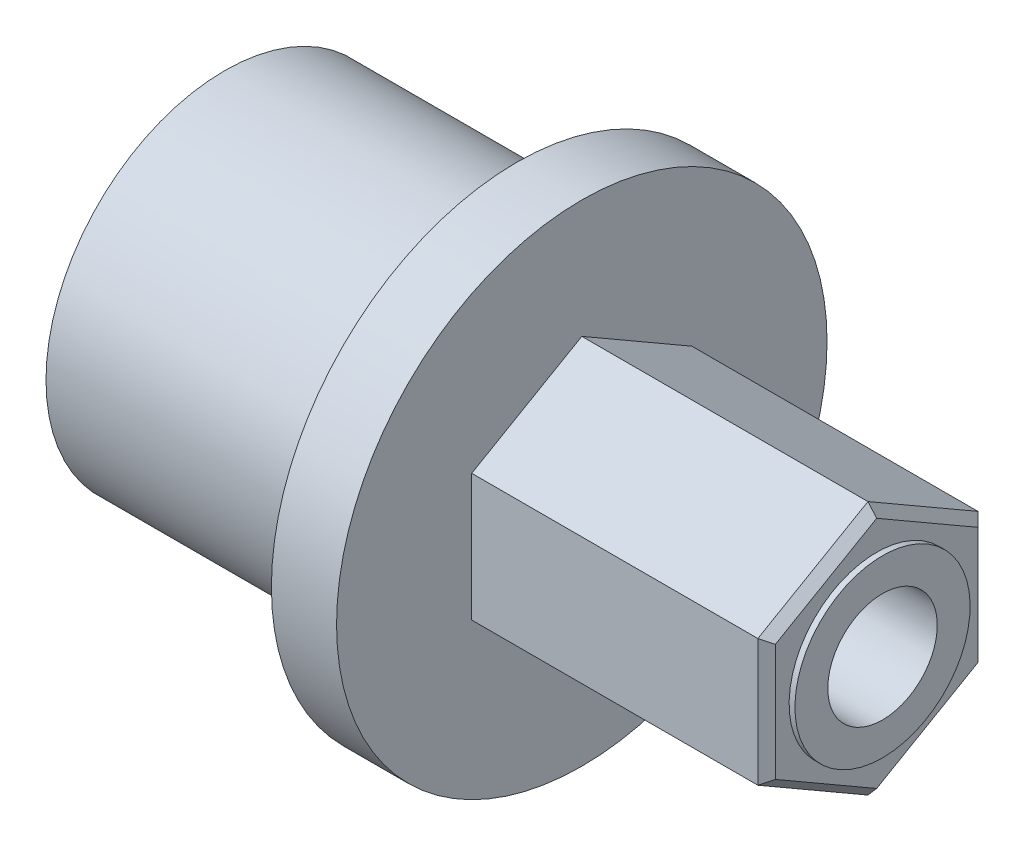
from build123d import *

# Parameters (mm, degrees)
SKETCH3_R           = 3.81
BOSS_EXTRUDE1_DEPTH = 12.827
CHAMFER1_SIZE       = 0.381


with BuildPart() as part:
    # Sketch1 → Revolve1 (revolve)
    with BuildSketch(Plane.XY):
        Polygon((-12.8778, 10.668), (-12.8778, 3.81), (0.2032, 3.81), (0.2032, 2.38125), (-24.036969082, 2.38125), (-28.412119082, 6.7564), (-28.412119082, 7.7724), (-15.712119082, 7.7724), (-15.712119082, 10.668), align=None)
    revolve(axis=Axis((-22.598839253, 0, 0), (1, 0, 0)))

    # Sketch3 → Boss-Extrude1 (add)
    with BuildSketch(Plane(origin=(-12.8778, 0, 0), x_dir=(0, 0, -1), z_dir=(1, 0, 0))):
        Polygon((-4.7879, 2.764295354), (-4.7879, -2.764295354), (0, -5.528590708), (4.7879, -2.764295354), (4.7879, 2.764295354), (0, 5.528590708), align=None)
        Circle(SKETCH3_R, mode=Mode.SUBTRACT)
    extrude(amount=BOSS_EXTRUDE1_DEPTH)

    # Chamfer1
    chamfer1_edges = [part.edges().sort_by_distance(p)[0] for p in [
        (-0.0508, 4.146443031, 2.39395),
        (-0.0508, 0, 4.7879),
        (-0.0508, -4.146443031, 2.39395),
        (-0.0508, -4.146443031, -2.39395),
        (-0.0508, 0, -4.7879),
        (-0.0508, 4.146443031, -2.39395),
    ]]
    chamfer(chamfer1_edges, length=CHAMFER1_SIZE)


solid = part.part
